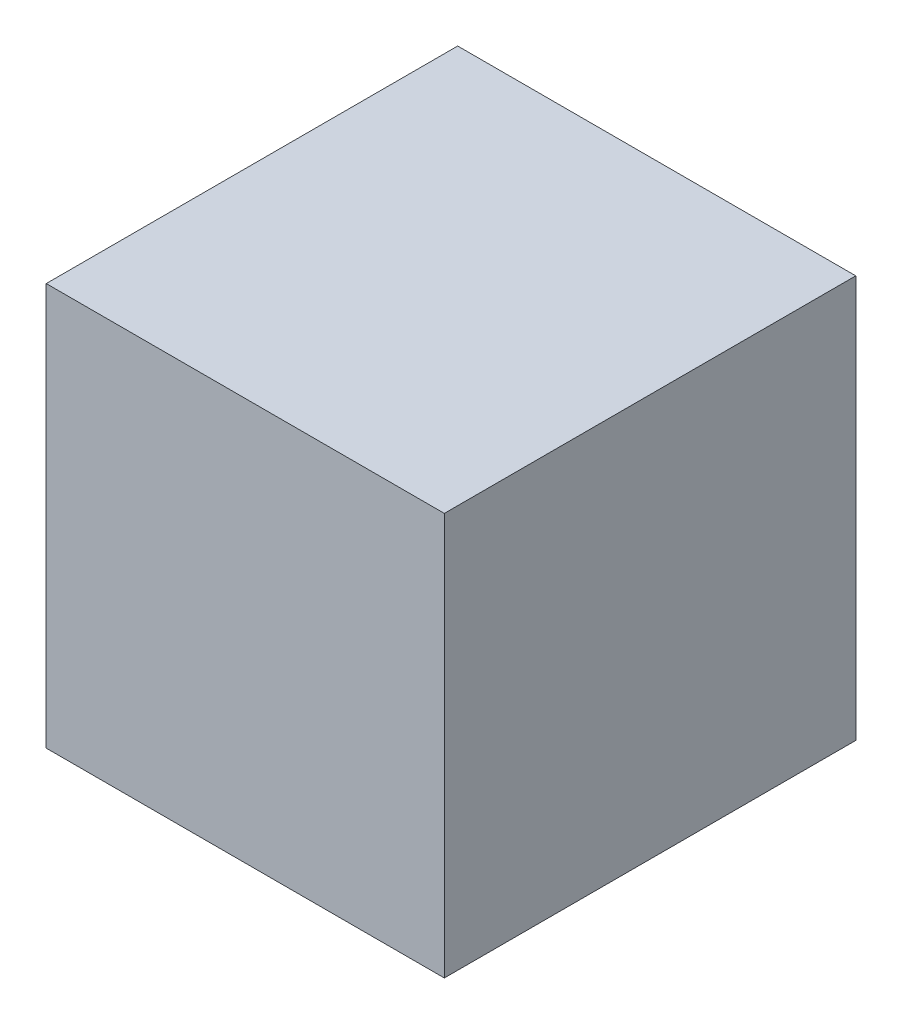
from build123d import *

# Parameters (mm, degrees)
SKETCH1_W           = 37.595768424
SKETCH1_H           = 38.857371392
BOSS_EXTRUDE1_DEPTH = 38


with BuildPart() as part:
    # Sketch1 → Boss-Extrude1 (new body)
    with BuildSketch(Plane(origin=(0, 0, 0), x_dir=(1, 0, 0), z_dir=(0, 1, 0))):
        with Locations((-59.926140945, 15.770037091)):
            Rectangle(SKETCH1_W, SKETCH1_H)
    extrude(amount=BOSS_EXTRUDE1_DEPTH)


solid = part.part
